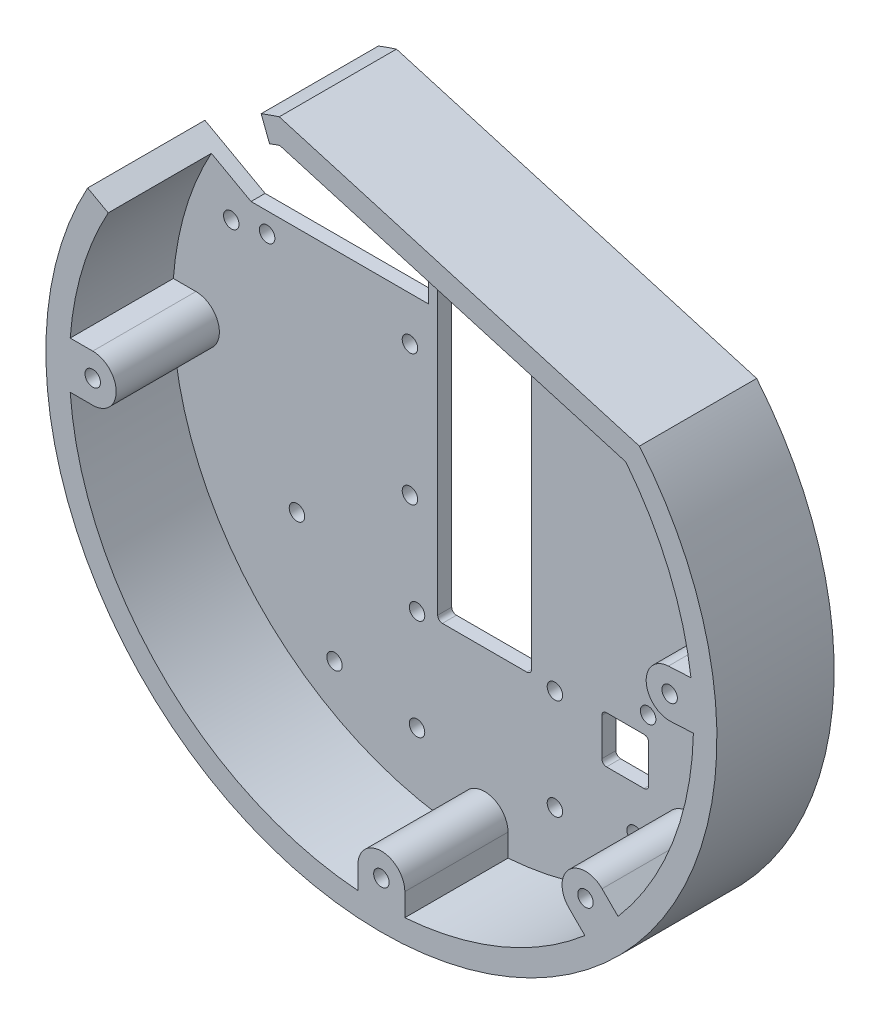
from build123d import *

# Parameters (mm, degrees)
SKETCH1_R                 = 71.545
SKETCH1_R_2               = 1.65
PLATE_EXTRUD_DEPTH        = 3
SKETCH2_R                 = 1.65
ARDUINO_MOUNT_HOLES_DEPTH = 3
CABLE_HOLE_DEPTH          = 102.224374782
SKETCH5_R                 = 1.65
RELAY_MOUNT_HOLES_DEPTH   = 102.224374782
SKETCH6_R                 = 1.65
BOSS_EXTRUDE3_DEPTH       = 25
CUT_EXTRUDE1_DEPTH        = 105.222713695
CUT_EXTRUDE2_START        = 22
CUT_EXTRUDE2_DEPTH        = 2.6
CUT_EXTRUDE3_DEPTH        = 105.222713695
BOSS_EXTRUDE4_DEPTH       = 10
BOSS_EXTRUDE4_DEPTH_BACK  = 10
CUT_EXTRUDE4_DEPTH        = 105.222713695
SKETCH12_R                = 1.65
CUT_EXTRUDE5_DEPTH        = 105.222713695


with BuildPart() as part:
    # Sketch1 → Plate extrud (new body)
    with BuildSketch(Plane(origin=(0, 0, 0), x_dir=(0, 1, 0), z_dir=(0, 0, 1))):
        Circle(SKETCH1_R)
        with Locations((-48.5, 32)):
            Circle(SKETCH1_R_2, mode=Mode.SUBTRACT)
        with Locations((22, 54)):
            Circle(SKETCH1_R_2, mode=Mode.SUBTRACT)
        with Locations((24, -52)):
            Circle(SKETCH1_R_2, mode=Mode.SUBTRACT)
        with Locations((-48.5, -32)):
            Circle(SKETCH1_R_2, mode=Mode.SUBTRACT)
    extrude(amount=PLATE_EXTRUD_DEPTH)

    # Sketch2 → Arduino mount holes (cut)
    with BuildSketch(Plane(origin=(0, 0, 0), x_dir=(0, 1, 0), z_dir=(0, 0, 1))):
        with Locations((-25, 40)):
            Circle(SKETCH2_R)
        with Locations((23.22, 46.36)):
            Circle(SKETCH2_R)
        with Locations((18.14, 15.91)):
            Circle(SKETCH2_R)
        with Locations((-9.77, 15.91)):
            Circle(SKETCH2_R)
        with Locations((-25, -34.88)):
            Circle(SKETCH2_R)
        with Locations((23.22, -36.11)):
            Circle(SKETCH2_R)
    extrude(amount=ARDUINO_MOUNT_HOLES_DEPTH, mode=Mode.SUBTRACT)

    # Sketch4 → Cable hole (cut, through all)
    with BuildSketch(Plane(origin=(0, 0, 0), x_dir=(0, 1, 0), z_dir=(0, 0, 1))):
        with BuildLine():
            Line((-29, 10), (49, 10))
            ThreePointArc((49, 10), (49.707106781, 9.707106781), (50, 9))
            Line((50, 9), (50, -9))
            ThreePointArc((50, -9), (49.707106781, -9.707106781), (49, -10))
            Line((49, -10), (-29, -10))
            ThreePointArc((-29, -10), (-29.707106781, -9.707106781), (-30, -9))
            Line((-30, -9), (-30, 9))
            ThreePointArc((-30, 9), (-29.707106781, 9.707106781), (-29, 10))
        make_face()
        with BuildLine():
            Line((-38, -25), (-30, -25))
            ThreePointArc((-30, -25), (-29.292893219, -25.292893219), (-29, -26))
            Line((-29, -26), (-29, -34))
            ThreePointArc((-29, -34), (-29.292893219, -34.707106781), (-30, -35))
            Line((-30, -35), (-38, -35))
            ThreePointArc((-38, -35), (-38.707106781, -34.707106781), (-39, -34))
            Line((-39, -34), (-39, -26))
            ThreePointArc((-39, -26), (-38.707106781, -25.292893219), (-38, -25))
        make_face()
    extrude(amount=CABLE_HOLE_DEPTH, mode=Mode.SUBTRACT)

    # Sketch5 → Relay mount holes (cut, through all)
    with BuildSketch(Plane(origin=(0, 0, 0), x_dir=(0, 1, 0), z_dir=(0, 0, 1))):
        with Locations((-52, -15)):
            Circle(SKETCH5_R)
        with Locations((-30.5, -15)):
            Circle(SKETCH5_R)
        with Locations((-30.5, 14.4)):
            Circle(SKETCH5_R)
        with Locations((-52, 14.4)):
            Circle(SKETCH5_R)
    extrude(amount=RELAY_MOUNT_HOLES_DEPTH, mode=Mode.SUBTRACT)

    # Sketch6 → Boss-Extrude3 (add)
    with BuildSketch(Plane(origin=(0, 0, 0), x_dir=(0, 1, 0), z_dir=(0, 0, 1))):
        with BuildLine():
            ThreePointArc((68.149505263, 21.779163377), (-68.679774221, 20.044341793), (45.736375855, -55.017005995))
            Line((45.736375855, -55.017005995), (68.149505263, 21.779163377))
        make_face()
        with BuildLine():
            Line((-61.545, 5), (-66.356891315, 5))
            ThreePointArc((-66.356891315, 5), (-47.054420754, 47.054420754), (-5, 66.356891315))
            Line((-5, 66.356891315), (-5, 61.545))
            ThreePointArc((-5, 61.545), (0, 56.545), (5, 61.545))
            Line((5, 61.545), (5, 66.356891315))
            ThreePointArc((5, 66.356891315), (40.644418881, 52.69030498), (62.91305896, 21.683727477))
            Line((62.91305896, 21.683727477), (41.373300987, -52.119928918))
            ThreePointArc((41.373300987, -52.119928918), (25.868565875, -61.311127249), (8.465999034, -66.004271721))
            Line((8.465999034, -66.004271721), (8.214164101, -61.198974935))
            ThreePointArc((8.214164101, -61.198974935), (2.959336646, -56.467507043), (-1.772131247, -61.722334498))
            Line((-1.772131247, -61.722334498), (-1.520296313, -66.527631283))
            ThreePointArc((-1.520296313, -66.527631283), (-23.847595202, -62.125109481), (-43.385873921, -50.456941733))
            Line((-43.385873921, -50.456941733), (-39.983352942, -47.054420754))
            ThreePointArc((-39.983352942, -47.054420754), (-39.983352942, -39.983352942), (-47.054420754, -39.983352942))
            Line((-47.054420754, -39.983352942), (-50.456941733, -43.385873921))
            ThreePointArc((-50.456941733, -43.385873921), (-61.479563491, -25.465669007), (-66.356891315, -5))
            Line((-66.356891315, -5), (-61.545, -5))
            ThreePointArc((-61.545, -5), (-56.545, 0), (-61.545, 5))
        make_face(mode=Mode.SUBTRACT)
        with Locations((-61.545, 0)):
            Circle(SKETCH6_R, mode=Mode.SUBTRACT)
        with Locations((0, 61.545)):
            Circle(SKETCH6_R, mode=Mode.SUBTRACT)
        with Locations((-43.518886848, -43.518886848)):
            Circle(SKETCH6_R, mode=Mode.SUBTRACT)
        with Locations((3.221016427, -61.460654716)):
            Circle(SKETCH6_R, mode=Mode.SUBTRACT)
    extrude(amount=BOSS_EXTRUDE3_DEPTH)

    # Sketch7 → Cut-Extrude1 (cut, through all)
    with BuildSketch(Plane.XY.offset(25)):
        with BuildLine():
            Line((-21.779163377, 68.149505263), (55.017005995, 45.736375855))
            ThreePointArc((55.017005995, 45.736375855), (20.044341793, 68.679774221), (-21.779163377, 68.149505263))
        make_face()
    extrude(amount=-CUT_EXTRUDE1_DEPTH, mode=Mode.SUBTRACT)

    # Sketch8 → Cut-Extrude2 (cut)
    with BuildSketch(Plane(origin=(0, 0, 0), x_dir=(0, 1, 0), z_dir=(0, 0, 1)).offset(CUT_EXTRUDE2_START)):
        Polygon((-60.154258671, 2.854675444), (-63.321850789, 2.631755043), (-64.712592118, -0.2229204), (-62.935741329, -2.854675444), (-59.768149211, -2.631755043), (-58.377407882, 0.2229204), align=None)
        Polygon((2.962348959, 60.401399554), (2.471561517, 63.53866923), (-0.490787442, 64.682269676), (-2.962348959, 62.688600446), (-2.471561517, 59.55133077), (0.490787442, 58.407730324), align=None)
        Polygon((6.396442908, -61.460654716), (4.808729667, -58.710654716), (1.633303187, -58.710654716), (0.045589946, -61.460654716), (1.633303187, -64.210654716), (4.808729667, -64.210654716), align=None)
        Polygon((-40.343460368, -43.518886848), (-41.931173608, -40.768886848), (-45.106600088, -40.768886848), (-46.694313329, -43.518886848), (-45.106600088, -46.268886848), (-41.931173608, -46.268886848), align=None)
    extrude(amount=-CUT_EXTRUDE2_DEPTH, mode=Mode.SUBTRACT)

    # Sketch9 → Cut-Extrude3 (cut, through all)
    with BuildSketch(Plane(origin=(0, 0, 0), x_dir=(0, 1, 0), z_dir=(0, 0, 1))):
        with BuildLine():
            Line((66.793011614, 25.63943495), (50, 19.193201752))
            Line((50, 19.193201752), (50, 12))
            Line((50, 12), (27.5, 12))
            Line((27.5, 12), (27.5, 49.795620732))
            Line((27.5, 49.795620732), (34.587369472, 62.629073903))
            ThreePointArc((34.587369472, 62.629073903), (53.95881545, 46.980136869), (66.793011614, 25.63943495))
        make_face()
    extrude(amount=CUT_EXTRUDE3_DEPTH, mode=Mode.SUBTRACT)

    # Sketch10 → Boss-Extrude4 (add, two sides: drawn at the far end of the back side and taken through both)
    with BuildSketch(Plane(origin=(0, 0, 0), x_dir=(0.7071067811865477, 0.7071067811865475, 0), z_dir=(-0.7071067811865475, 0.7071067811865477, 0)).offset(-BOSS_EXTRUDE4_DEPTH_BACK)):
        with BuildLine():
            Line((-67.545, 0), (-76.045, 0))
            ThreePointArc((-76.045, 0), (-76.752106781, -0.292893219), (-77.045, -1))
            Line((-77.045, -1), (-77.045, -9))
            ThreePointArc((-77.045, -9), (-76.752106781, -9.707106781), (-76.045, -10))
            Line((-76.045, -10), (-67.545, -10))
            Line((-67.545, -10), (-67.545, 0))
        make_face()
        with BuildLine():
            Line((-72.545, -2.5), (-72.545, -7.5))
            ThreePointArc((-72.545, -7.5), (-74.045, -9), (-75.545, -7.5))
            Line((-75.545, -7.5), (-75.545, -2.5))
            ThreePointArc((-75.545, -2.5), (-74.045, -1), (-72.545, -2.5))
        make_face(mode=Mode.SUBTRACT)
    extrude(amount=BOSS_EXTRUDE4_DEPTH + BOSS_EXTRUDE4_DEPTH_BACK)

    # Sketch11 → Cut-Extrude4 (cut, through all)
    with BuildSketch(Plane(origin=(0, 0, 0), x_dir=(0, 1, 0), z_dir=(0, 0, 1))):
        with BuildLine():
            Line((-54.654380515, 46.169099141), (-58.721682644, 50.236401269))
            Line((-58.721682644, 50.236401269), (-50.236401269, 58.721682644))
            Line((-50.236401269, 58.721682644), (-46.169099141, 54.654380515))
            ThreePointArc((-46.169099141, 54.654380515), (-50.58995466, 50.58995466), (-54.654380515, 46.169099141))
        make_face()
    extrude(amount=CUT_EXTRUDE4_DEPTH, mode=Mode.SUBTRACT)

    # Sketch12 → Cut-Extrude5 (cut, through all)
    with BuildSketch(Plane(origin=(0, 0, 0), x_dir=(0, 1, 0), z_dir=(0, 0, 1))):
        with Locations((30.82, -29.5)):
            Circle(SKETCH12_R)
        with Locations((40.18, -29.5)):
            Circle(SKETCH12_R)
    extrude(amount=CUT_EXTRUDE5_DEPTH, mode=Mode.SUBTRACT)


solid = part.part
